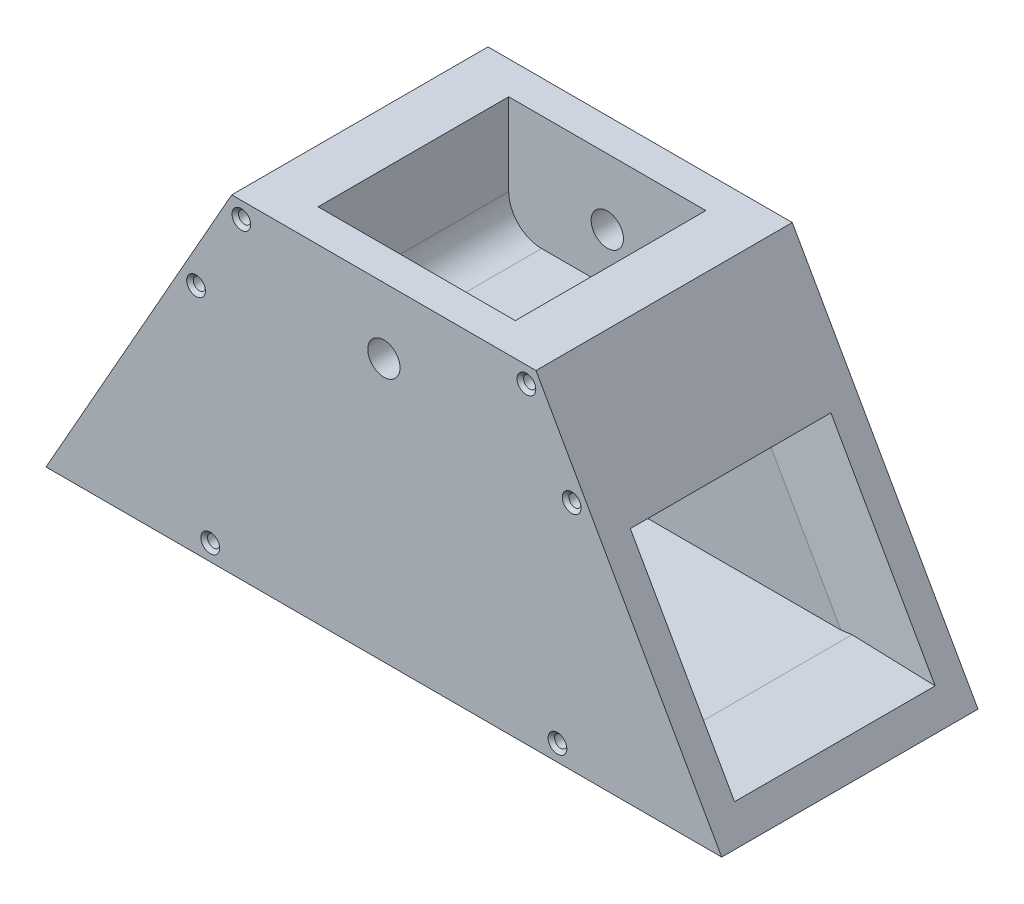
from build123d import *
from OCP.BRepFilletAPI import BRepFilletAPI_MakeChamfer

# Parameters (mm, degrees)
BOSS_EXTRUDE1_DEPTH     = 78
SKETCH3_W               = 54
SKETCH3_H               = 49
CUT_EXTRUDE1_DEPTH      = 164.27356518
CUT_EXTRUDE1_DEPTH_BACK = 164.27356518
CHAMFER1_SIZE           = 20
CHAMFER1_SIZE2          = 4.499551712
CHAMFER1_SIZE2_2        = 3.526539614
CHAMFER1_SIZE2_3        = 3.683833732
CUT_EXTRUDE2_DEPTH      = 164.27356518
SKETCH8_W               = 60
SKETCH8_H               = 46.143990022
SKETCH8_R               = 4.91
BOSS_EXTRUDE4_DEPTH     = 10
BOSS_EXTRUDE5_START     = -78
SKETCH8_3_W             = 60
SKETCH8_3_H             = 46.143990022
SKETCH8_3_R             = 4.91
BOSS_EXTRUDE5_DEPTH     = 10
SKETCH10_R              = 1.85
CUT_EXTRUDE4_DEPTH      = 164.27356518
CHAMFER2_SIZE           = 1


with BuildPart() as part:
    # Sketch2 → Boss-Extrude1 (new body)
    with BuildSketch(Plane.XY):
        Polygon((46.3, 100), (-46.3, 100), (-102.831206773, 0), (102.831206773, 0), align=None)
    extrude(amount=BOSS_EXTRUDE1_DEPTH)

    # Sketch3 → Cut-Extrude1 (cut, two sides)
    with BuildSketch(Plane(origin=(0, 0, 0), x_dir=(0, 0, -1), z_dir=(1, 0, 0))) as cut_extrude1_sk:
        with Locations((-39, 36.5)):
            Rectangle(SKETCH3_W, SKETCH3_H)
    extrude(amount=CUT_EXTRUDE1_DEPTH, mode=Mode.SUBTRACT)
    extrude(cut_extrude1_sk.sketch, amount=-CUT_EXTRUDE1_DEPTH_BACK, mode=Mode.SUBTRACT)

    # Chamfer1: one chamfer whose edges measure the first distance from different faces: ONE call of the kernel's chamfer builder (chamfer() names one face for all edges)
    chamfer1_edges_1 = [part.edges().sort_by_distance(p)[0] for p in [
        (96.04746196, 12, 39),
        (-96.04746196, 12, 39),
    ]]
    chamfer1_side_1 = [part.faces().sort_by_distance(p)[0] for p in [
        (0, 12, 39),
    ]]
    chamfer1_edges_2 = [part.edges().sort_by_distance(p)[0] for p in [
        (82.197316301, 36.5, 12),
        (-82.197316301, 36.5, 12),
    ]]
    chamfer1_side_2 = [part.faces().sort_by_distance(p)[0] for p in [
        (0, 35.123926814, 12),
    ]]
    chamfer1_edges_3 = [part.edges().sort_by_distance(p)[0] for p in [
        (68.347170642, 61, 39),
        (-68.347170642, 61, 39),
    ]]
    chamfer1_side_3 = [part.faces().sort_by_distance(p)[0] for p in [
        (0, 61, 39),
    ]]
    chamfer1_edges_4 = [part.edges().sort_by_distance(p)[0] for p in [
        (82.197316301, 36.5, 66),
        (-82.197316301, 36.5, 66),
    ]]
    chamfer1_side_4 = [part.faces().sort_by_distance(p)[0] for p in [
        (0, 35.123926814, 66),
    ]]
    chamfer1 = BRepFilletAPI_MakeChamfer(part.part.solid().wrapped)
    for e in chamfer1_edges_1:
        chamfer1.Add(CHAMFER1_SIZE, CHAMFER1_SIZE2, e.wrapped, chamfer1_side_1[0].wrapped)  # the first distance lies on this face
    for e in chamfer1_edges_2:
        chamfer1.Add(CHAMFER1_SIZE, CHAMFER1_SIZE2_2, e.wrapped, chamfer1_side_2[0].wrapped)  # the first distance lies on this face
    for e in chamfer1_edges_3:
        chamfer1.Add(CHAMFER1_SIZE, CHAMFER1_SIZE2_3, e.wrapped, chamfer1_side_3[0].wrapped)  # the first distance lies on this face
    for e in chamfer1_edges_4:
        chamfer1.Add(CHAMFER1_SIZE, CHAMFER1_SIZE2_2, e.wrapped, chamfer1_side_4[0].wrapped)  # the first distance lies on this face
    add(Compound.cast(chamfer1.Shape()), mode=Mode.REPLACE)

    # Sketch4 → Cut-Extrude2 (cut, through all)
    with BuildSketch(Plane.XY.offset(78)):
        with BuildLine():
            Line((-20, 65), (20, 65))
            ThreePointArc((20, 65), (27.071067812, 67.928932188), (30, 75))
            Line((30, 75), (30, 100))
            Line((30, 100), (-30, 100))
            Line((-30, 100), (-30, 75))
            ThreePointArc((-30, 75), (-27.071067812, 67.928932188), (-20, 65))
        make_face()
    extrude(amount=-CUT_EXTRUDE2_DEPTH, mode=Mode.SUBTRACT)

    # Sketch8 → Boss-Extrude4 (add)
    with BuildSketch(Plane.XY.offset(78)):
        with Locations((0, 76.928004989)):
            Rectangle(SKETCH8_W, SKETCH8_H)
        with Locations((0, 80)):
            Circle(SKETCH8_R, mode=Mode.SUBTRACT)
    extrude(amount=-BOSS_EXTRUDE4_DEPTH)

    # Sketch8_3 → Boss-Extrude5 (add)
    with BuildSketch(Plane.XY.offset(78).offset(BOSS_EXTRUDE5_START)):
        with Locations((0, 76.928004989)):
            Rectangle(SKETCH8_3_W, SKETCH8_3_H)
        with Locations((0, 80)):
            Circle(SKETCH8_3_R, mode=Mode.SUBTRACT)
    extrude(amount=BOSS_EXTRUDE5_DEPTH)

    # Sketch10 → Cut-Extrude4 (cut, through all)
    with BuildSketch(Plane.XY.offset(78)):
        with Locations((-43.382916604, 95)):
            Circle(SKETCH10_R)
        with Locations((-57.162268727, 70.625229128)):
            Circle(SKETCH10_R)
        with Locations((-52.831206773, 5)):
            Circle(SKETCH10_R)
        with Locations(Location((52.831206773, 5, 0), (0, 0, 180))):
            Circle(SKETCH10_R)
        with Locations(Location((57.162268727, 70.625229128, 0), (0, 0, 180))):
            Circle(SKETCH10_R)
        with Locations(Location((43.382916604, 95, 0), (0, 0, 180))):
            Circle(SKETCH10_R)
    extrude(amount=-CUT_EXTRUDE4_DEPTH, mode=Mode.SUBTRACT)

    # Chamfer2
    chamfer2_edges = [part.edges().sort_by_distance(p)[0] for p in [
        (45.232916604, 95, 0),
        (45.232916604, 95, 78),
        (59.012268727, 70.625229128, 0),
        (59.012268727, 70.625229128, 78),
        (54.681206773, 5, 0),
        (54.681206773, 5, 78),
        (-54.681206773, 5, 0),
        (-54.681206773, 5, 78),
        (-59.012268727, 70.625229128, 0),
        (-59.012268727, 70.625229128, 78),
        (-45.232916604, 95, 0),
        (-45.232916604, 95, 78),
    ]]
    chamfer(chamfer2_edges, length=CHAMFER2_SIZE)


solid = part.part
